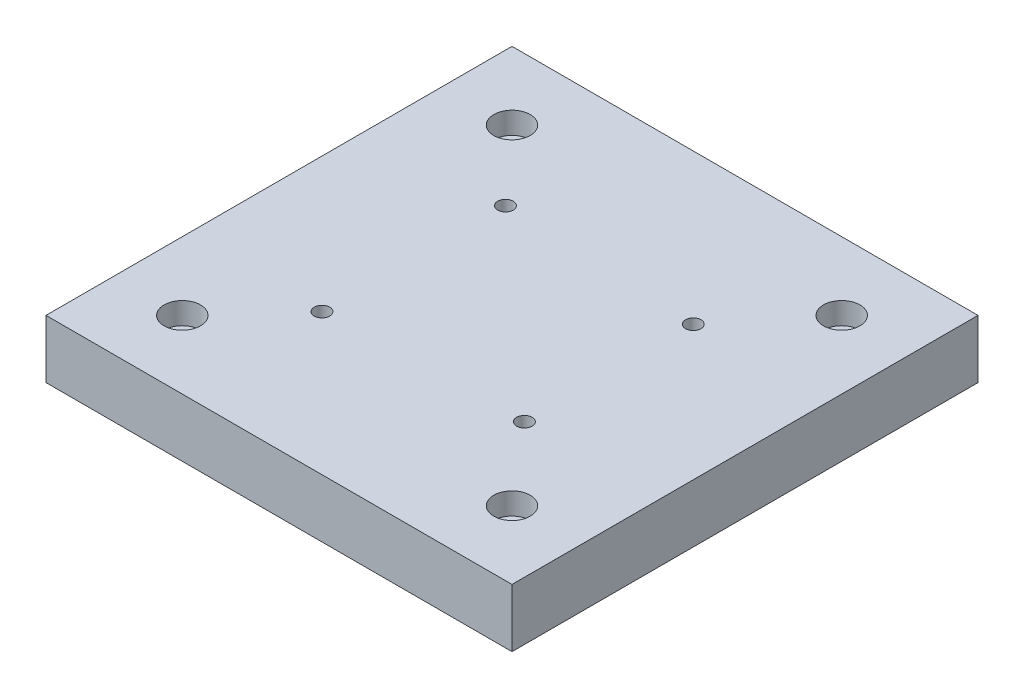
from build123d import *

# Parameters (mm, degrees)
SKETCH1_W                                        = 203.2
SKETCH1_H                                        = 203.2
BOSS_EXTRUDE1_DEPTH                              = 25.4
CBORE_FOR_1_4_SOCKET_HEAD_CAP_SCREW1_D           = 6.7564
CBORE_FOR_1_4_SOCKET_HEAD_CAP_SCREW1_CBORE_D     = 11.1125
CBORE_FOR_1_4_SOCKET_HEAD_CAP_SCREW1_CBORE_DEPTH = 18.3500014
CBORE_FOR_3_8_SOCKET_HEAD_CAP_SCREW1_D           = 10.0838
CBORE_FOR_3_8_SOCKET_HEAD_CAP_SCREW1_CBORE_D     = 15.875
CBORE_FOR_3_8_SOCKET_HEAD_CAP_SCREW1_CBORE_DEPTH = 9.525


with BuildPart() as part:
    # Sketch1 → Boss-Extrude1 (new body)
    with BuildSketch(Plane(origin=(0, 0, 0), x_dir=(1, 0, 0), z_dir=(0, 1, 0))):
        with Locations((101.6, 101.6)):
            Rectangle(SKETCH1_W, SKETCH1_H)
    extrude(amount=BOSS_EXTRUDE1_DEPTH)

    # CBORE for 1/4 Socket Head Cap Screw1 (through all)
    with Locations(Plane(origin=(0, 0, 0), x_dir=(-1, 0, 0), z_dir=(0, -1, 0))):
        with Locations((-144.4625, 64.135), (-58.7375, 61.595), (-58.7375, 141.605), (-144.4625, 137.795)):
            CounterBoreHole(CBORE_FOR_1_4_SOCKET_HEAD_CAP_SCREW1_D / 2, CBORE_FOR_1_4_SOCKET_HEAD_CAP_SCREW1_CBORE_D / 2, CBORE_FOR_1_4_SOCKET_HEAD_CAP_SCREW1_CBORE_DEPTH)

    # CBORE for 3/8 Socket Head Cap Screw1 (through all)
    with Locations(Plane(origin=(0, 25.4, 0), x_dir=(1, 0, 0), z_dir=(0, 1, 0))):
        with Locations((29.718, 173.482), (29.718, 29.718), (173.482, 29.718), (173.482, 173.482)):
            CounterBoreHole(CBORE_FOR_3_8_SOCKET_HEAD_CAP_SCREW1_D / 2, CBORE_FOR_3_8_SOCKET_HEAD_CAP_SCREW1_CBORE_D / 2, CBORE_FOR_3_8_SOCKET_HEAD_CAP_SCREW1_CBORE_DEPTH)


solid = part.part
